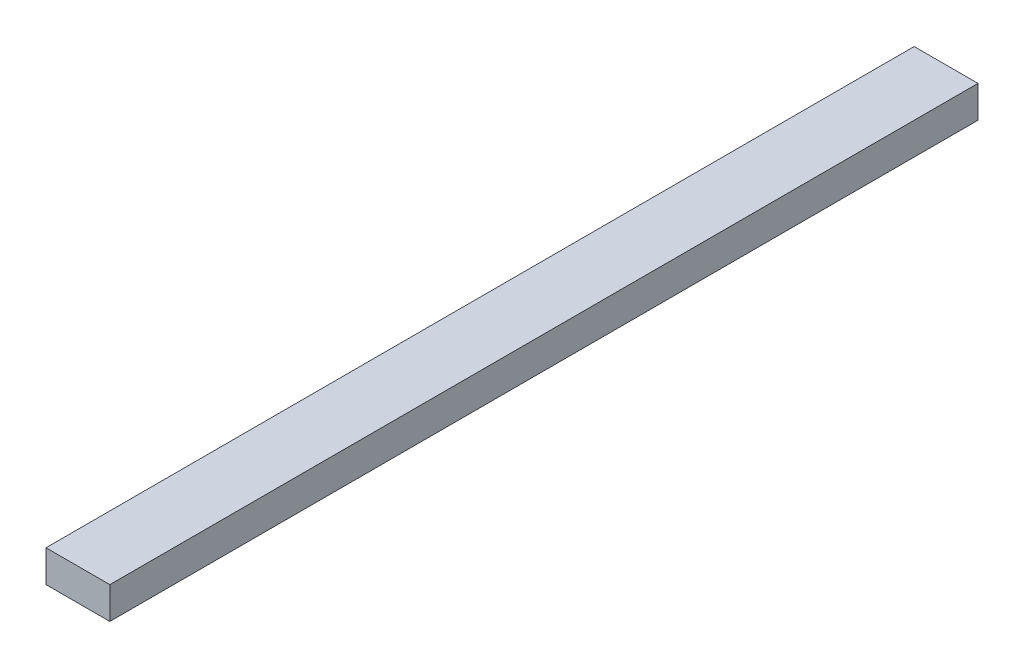
from build123d import *

# Parameters (mm, degrees)
SKETCH1_W           = 12.7
SKETCH1_H           = 6.35
BOSS_EXTRUDE1_DEPTH = 172.72


with BuildPart() as part:
    # Sketch1 → Boss-Extrude1 (new body)
    with BuildSketch(Plane.XY):
        with Locations((6.35, 3.175)):
            Rectangle(SKETCH1_W, SKETCH1_H)
    extrude(amount=BOSS_EXTRUDE1_DEPTH)


solid = part.part
